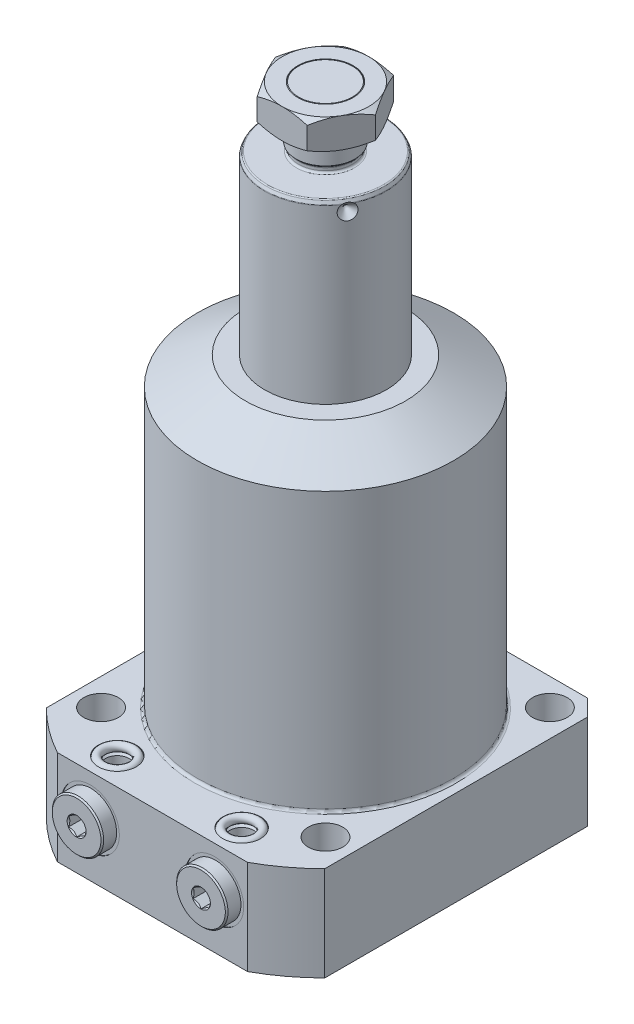
from build123d import *

# Parameters (mm, degrees)
FILLET2_R           = 0.75
FILLET3_R           = 0.5
SKETCH3_R           = 10.25
EXTRUDE3_DEPTH      = 11
CIRPATTERN1_COUNT   = 3
SKETCH7_OUTSIDE_W   = 210.698
SKETCH7_OUTSIDE_H   = 210.698
SKETCH7_OUTSIDE_W_2 = 103
SKETCH7_OUTSIDE_H_2 = 115.5
CUT_EXTRUDE5_DEPTH  = 36
SKETCH8_R           = 6.4
CUT_EXTRUDE6_DEPTH  = 36
CIRPATTERN2_COUNT   = 4
CHAMFER1_SIZE       = 6
FILLET5_R           = 1
CUT_EXTRUDE8_DEPTH  = 5.3
SKETCH16_R          = 1.5


with BuildPart() as part:
    # Sketch1 → Revolve2 (revolve)
    with BuildSketch(Plane.XY, mode=Mode.PRIVATE) as revolve2_sk:
        Polygon((22.5, 0), (22.5, 176.75), (21.800538513, 178.25), (10, 178.25), (10, 180.25), (10.935, 181.185), (10.935, 199.5), (9.935, 200.5), (0, 200.5), (0, 0), align=None)
    revolve(revolve2_sk.sketch.rotate(Axis((0, -3.075, 0), (0, 1, 0)), 90), axis=Axis((0, -3.075, 0), (0, 1, 0)))  # turned: the seam where the file's is

    # Fillet2
    fillet2_edges = [part.edges().sort_by_distance(p)[0] for p in [
        (0, 178.25, 10),
        (0, 180.25, 10),
    ]]
    fillet(fillet2_edges, radius=FILLET2_R)

    # Fillet3
    fillet3_edges = [part.edges().sort_by_distance(p)[0] for p in [
        (0, 176.75, 22.5),
        (0, 178.25, 21.800538513),
    ]]
    fillet(fillet3_edges, radius=FILLET3_R)

    # Sketch2 → Cut-Revolve1 (revolve, cut)
    with BuildSketch(Plane(origin=(0, 0, 0), x_dir=(0, 0, -1), z_dir=(1, 0, 0)), mode=Mode.PRIVATE) as cut_revolve1_sk:
        Polygon((19.5, 174.25), (22.5, 171.25), (22.5, 174.25), align=None)
    cut_revolve1 = revolve(cut_revolve1_sk.sketch.rotate(Axis((0, 174.25, -4.20155099), (0, 0, -1)), 90), axis=Axis((0, 174.25, -4.20155099), (0, 0, -1)), mode=Mode.SUBTRACT)  # turned: the seam where the file's is

    # Sketch3 → Extrude3 (add)
    with BuildSketch(Plane(origin=(0, 200.5, 0), x_dir=(1, 0, 0), z_dir=(0, 1, 0))):
        Polygon((18.475208614, 0), (9.237604307, 16), (-9.237604307, 16), (-18.475208614, 0), (-9.237604307, -16), (9.237604307, -16), align=None)
        with Locations(Location((0, 0, 0), (0, 0, 270))):  # turned: the seam where the file's is
            Circle(SKETCH3_R, mode=Mode.SUBTRACT)
    extrude(amount=-EXTRUDE3_DEPTH)

    # CirPattern1: Cut-Revolve1 ×3 about axis
    cirpattern1_axis = Axis((0, -3.075, 0), (0, -1, 0))
    for i in range(1, CIRPATTERN1_COUNT):
        add(cut_revolve1.rotate(cirpattern1_axis, i * 360 / CIRPATTERN1_COUNT), mode=Mode.SUBTRACT)

    # Sketch4 → Cut-Revolve3 (revolve, cut)
    with BuildSketch(Plane(origin=(0, 0, 0), x_dir=(0, 0, -1), z_dir=(1, 0, 0))):
        Polygon((16, 200.5), (19, 200.5), (19, 198.767949192), align=None)
        Polygon((19, 191.232050808), (16, 189.5), (19, 189.5), align=None)
    revolve(axis=Axis((0, -3.075, 0), (0, -1, 0)), mode=Mode.SUBTRACT)

    # Sketch6 → Revolve3 (revolve)
    with BuildSketch(Plane.XY, mode=Mode.PRIVATE) as revolve3_sk:
        Polygon((0, 113), (29.625, 113), (47.385, 102.746259219), (47.385, 0), (73.025, 0), (73.025, -35), (0, -35), align=None)
    revolve(revolve3_sk.sketch.rotate(Axis((0, 0, 0), (0, 1, 0)), 90), axis=Axis((0, 0, 0), (0, 1, 0)))  # turned: the seam where the file's is

    # Sketch7 outside → Cut-Extrude5 (cut, through all)
    with BuildSketch(Plane(origin=(0, 0, 0), x_dir=(-1, 0, 0), z_dir=(0, 1, 0))):
        Rectangle(SKETCH7_OUTSIDE_W, SKETCH7_OUTSIDE_H)
        with Locations((0, 6.25)):
            Rectangle(SKETCH7_OUTSIDE_W_2, SKETCH7_OUTSIDE_H_2, mode=Mode.SUBTRACT)
    extrude(amount=-CUT_EXTRUDE5_DEPTH, mode=Mode.SUBTRACT)

    # Sketch8 → Cut-Extrude6 (cut, through all)
    with BuildSketch(Plane(origin=(0, 0, 0), x_dir=(-1, 0, 0), z_dir=(0, 1, 0))):
        with Locations(Location((-41.5, 41.5, 0), (0, 0, 90))):  # turned: the seam where the file's is
            Circle(SKETCH8_R)
    cut_extrude6 = extrude(amount=-CUT_EXTRUDE6_DEPTH, mode=Mode.SUBTRACT)

    # CirPattern2: Cut-Extrude6 ×4 about axis
    cirpattern2_axis = Axis((0, 0, 0), (0, 1, 0))
    for i in range(1, CIRPATTERN2_COUNT):
        add(cut_extrude6.rotate(cirpattern2_axis, i * 360 / CIRPATTERN2_COUNT), mode=Mode.SUBTRACT)

    # Chamfer1
    chamfer1_edges = [part.edges().sort_by_distance(p)[0] for p in [
        (-51.5, -17.5, -51.5),
        (51.5, -17.5, -51.5),
    ]]
    chamfer(chamfer1_edges, length=CHAMFER1_SIZE)

    # Fillet5
    fillet5_edges = [part.edges().sort_by_distance(p)[0] for p in [
        (0, 0, 47.385),
    ]]
    fillet(fillet5_edges, radius=FILLET5_R)

    # Sketch11 → Cut-Revolve5 (revolve, cut)
    with BuildSketch(Plane(origin=(0, -15, 0), x_dir=(-1, 0, 0), z_dir=(0, 1, 0))):
        Polygon((-33.75, 64), (-33.75, 63.75), (-29.65, 63.75), (-28.945, 63.045), (-28.945, 45.03), (-23, 45.03), (-23, 64), align=None)
    cut_revolve5 = revolve(axis=Axis((23, -15, 42.971570338), (0, 0, -1)), mode=Mode.SUBTRACT)

    # Sketch13 → Cut-Revolve6 (revolve, cut)
    with BuildSketch(Plane.XY.offset(54)):
        Polygon((-27.375, -23), (-27.375, -32), (-28.125, -32.75), (-30, -32.75), (-30, -35), (-23, -35), (-23, -23), align=None)
        Polygon((-23, -12), (-27.375, -12), (-27.375, -3), (-28.125, -2.25), (-30, -2.25), (-30, 0), (-23, 0), align=None)
    cut_revolve6 = revolve(axis=Axis((-23, 15.209907045, 54), (0, -1, 0)), mode=Mode.SUBTRACT)

    # Sketch14 → Revolve6 (revolve)
    with BuildSketch(Plane(origin=(0, -15, 0), x_dir=(-1, 0, 0), z_dir=(0, 1, 0)), mode=Mode.PRIVATE) as revolve6_sk:
        Polygon((-26.5, 69.05), (-32, 69.05), (-32.5, 68.55), (-32.5, 63.75), (-28.6, 63.75), (-28.6, 61.24741814), (-23, 61.24741814), (-23, 61.24841814), (-26, 63.050999997), (-26, 68.55), align=None)
    revolve6 = revolve(revolve6_sk.sketch.rotate(Axis((23, -15, 32.588064048), (0, 0, 1)), 180), axis=Axis((23, -15, 32.588064048), (0, 0, 1)))  # turned: the seam where the file's is

    # Sketch15 → Cut-Extrude8 (cut)
    with BuildSketch(Plane.XY.offset(69.05)):
        Polygon((26, -16.732050808), (26, -13.267949192), (23, -11.535898385), (20, -13.267949192), (20, -16.732050808), (23, -18.464101615), align=None)
    cut_extrude8 = extrude(amount=-CUT_EXTRUDE8_DEPTH, mode=Mode.SUBTRACT)

    # Mirror1: Cut-Revolve5, Cut-Revolve6, Revolve6, Cut-Extrude8 across plane
    add(cut_revolve5.mirror(Plane(origin=(0, 0, 0), x_dir=(0, 0, 1), z_dir=(1, 0, 0))), mode=Mode.SUBTRACT)
    add(cut_revolve6.mirror(Plane(origin=(0, 0, 0), x_dir=(0, 0, 1), z_dir=(1, 0, 0))), mode=Mode.SUBTRACT)
    add(revolve6.mirror(Plane(origin=(0, 0, 0), x_dir=(0, 0, 1), z_dir=(1, 0, 0))))
    add(cut_extrude8.mirror(Plane(origin=(0, 0, 0), x_dir=(0, 0, 1), z_dir=(1, 0, 0))), mode=Mode.SUBTRACT)


with BuildPart() as body_2:
    # Sketch16 → Revolve7 (revolve)
    with BuildSketch(Plane.XY.offset(54)):
        with Locations((-28.5, -0.75)):
            Circle(SKETCH16_R)
        with Locations((-28.5, -34.25)):
            Circle(SKETCH16_R)
    revolve(axis=Axis((-23, 9.321927472, 54), (0, -1, 0)))


with BuildPart() as body_3:
    # Mirror3: mirrored copy
    add(body_2.part.mirror(Plane(origin=(0, 0, 0), x_dir=(0, 0, 1), z_dir=(1, 0, 0))))


solid = Compound([part.part, body_2.part, body_3.part])
